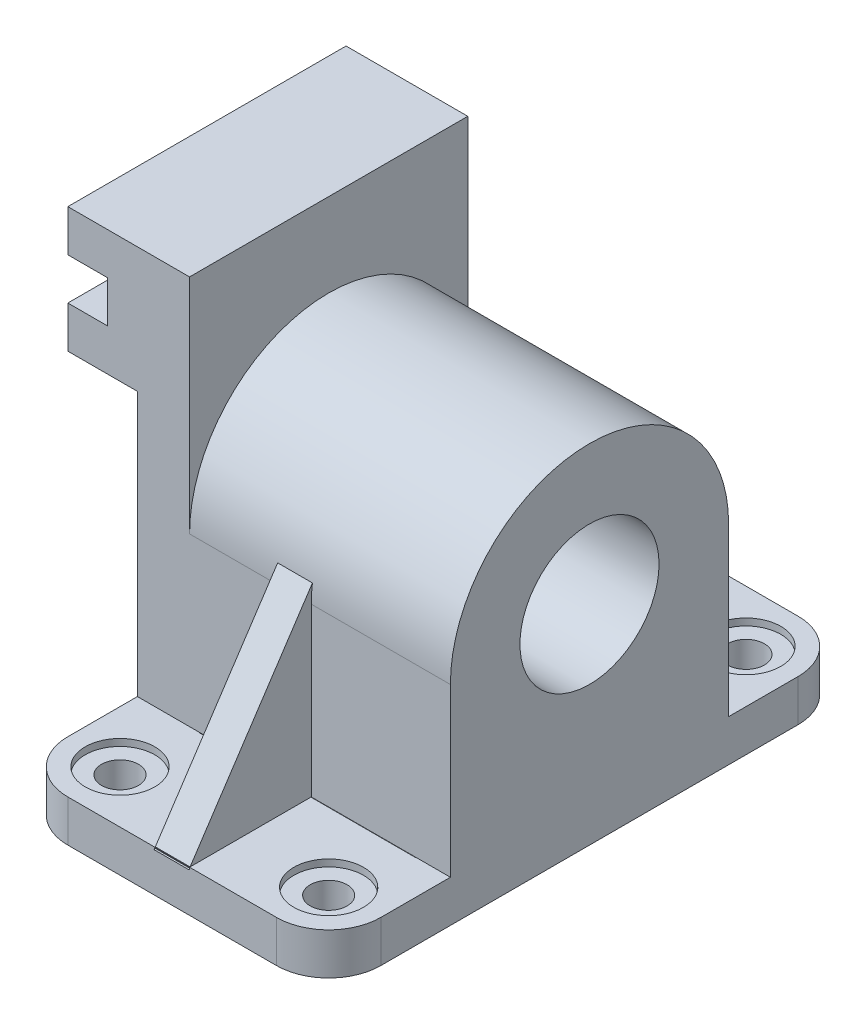
from build123d import *

# Parameters (mm, degrees)
CROQUIS1_R              = 10
SALIENTE_EXTRUIR1_DEPTH = 22.5
CROQUIS3_R              = 2.65
SALIENTE_EXTRUIR2_DEPTH = 6
CROQUIS5_R              = 5
CORTAR_EXTRUIR1_DEPTH   = 1
SALIENTE_EXTRUIR3_DEPTH = 20
CROQUIS8_R              = 10
CORTAR_EXTRUIR2_DEPTH   = 45
SALIENTE_EXTRUIR4_DEPTH = 2.5
CROQUIS15_W             = 31.132875884
CROQUIS15_H             = 39.860662673
CORTAR_EXTRUIR3_DEPTH   = 6


with BuildPart() as part:
    # Croquis1 → Saliente-Extruir1 (new body, symmetric)
    with BuildSketch(Plane(origin=(0, 0, 0), x_dir=(0, 0, -1), z_dir=(1, 0, 0))):
        with BuildLine():
            Line((-20, -24), (20, -24))
            Line((20, -24), (20, 0))
            ThreePointArc((20, 0), (0, 20), (-20, 0))
            Line((-20, 0), (-20, -24))
        make_face()
        Circle(CROQUIS1_R, mode=Mode.SUBTRACT)
    extrude(amount=SALIENTE_EXTRUIR1_DEPTH, both=True)

    # Croquis3 → Saliente-Extruir2 (add)
    with BuildSketch(Plane(origin=(0, -24, 0), x_dir=(-1, 0, 0), z_dir=(0, -1, 0))):
        with BuildLine():
            Line((22.5, 30), (22.5, 18.749800444))
            Line((22.5, 18.749800444), (22.5, -30))
            ThreePointArc((22.5, -30), (20.303300859, -35.303300859), (15, -37.5))
            Line((15, -37.5), (-15, -37.5))
            ThreePointArc((-15, -37.5), (-20.303300859, -35.303300859), (-22.5, -30))
            Line((-22.5, -30), (-22.5, 30))
            ThreePointArc((-22.5, 30), (-20.303300859, 35.303300859), (-15, 37.5))
            Line((-15, 37.5), (15, 37.5))
            ThreePointArc((15, 37.5), (20.303300859, 35.303300859), (22.5, 30))
        make_face()
        with Locations((15, 30)):
            Circle(CROQUIS3_R, mode=Mode.SUBTRACT)
        with Locations((-15, 30)):
            Circle(CROQUIS3_R, mode=Mode.SUBTRACT)
        with Locations((15, -30)):
            Circle(CROQUIS3_R, mode=Mode.SUBTRACT)
        with Locations((-15, -30)):
            Circle(CROQUIS3_R, mode=Mode.SUBTRACT)
    extrude(amount=SALIENTE_EXTRUIR2_DEPTH)

    # Croquis5 → Cortar-Extruir1 (cut)
    with BuildSketch(Plane(origin=(0, -24, 0), x_dir=(-1, 0, 0), z_dir=(0, -1, 0))):
        with Locations((15, 30)):
            Circle(CROQUIS5_R)
        with Locations((-15, 30)):
            Circle(CROQUIS5_R)
        with Locations((15, -30)):
            Circle(CROQUIS5_R)
        with Locations((-15, -30)):
            Circle(CROQUIS5_R)
    extrude(amount=CORTAR_EXTRUIR1_DEPTH, mode=Mode.SUBTRACT)

    # Croquis6 → Saliente-Extruir3 (add, symmetric)
    with BuildSketch(Plane.XY):
        Polygon((-15, 20.067860351), (-15, 32), (-32.5, 32), (-32.5, 26), (-26.787274513, 26), (-26.787274513, 20), (-32.5, 20), (-32.5, 14), (-22.5, 14), (-22.5, 0), (-15, 0), align=None)
    extrude(amount=SALIENTE_EXTRUIR3_DEPTH, both=True)

    # Croquis8 → Cortar-Extruir2 (cut)
    with BuildSketch(Plane.ZY.offset(22.5)):
        Circle(CROQUIS8_R)
    extrude(amount=-CORTAR_EXTRUIR2_DEPTH, mode=Mode.SUBTRACT)

    # Croquis10 → Saliente-Extruir4 (add, symmetric)
    with BuildSketch(Plane(origin=(0, 0, 0), x_dir=(0, 0, -1), z_dir=(1, 0, 0))):
        Polygon((-18.138791867, 5.125023494), (-37.598536218, -24.265305437), (-18.138791867, -24.265305437), align=None)
        Polygon((37.025889105, -24.265305437), (19.948399075, -24.265305437), (19.948399075, 5.125023494), align=None)
    extrude(amount=SALIENTE_EXTRUIR4_DEPTH, both=True)

    # Croquis15 → Cortar-Extruir3 (cut)
    with BuildSketch(Plane.XZ.offset(30)):
        with Locations((1.933562058, 0.121457578)):
            Rectangle(CROQUIS15_W, CROQUIS15_H)
    extrude(amount=-CORTAR_EXTRUIR3_DEPTH, mode=Mode.SUBTRACT)


solid = part.part
